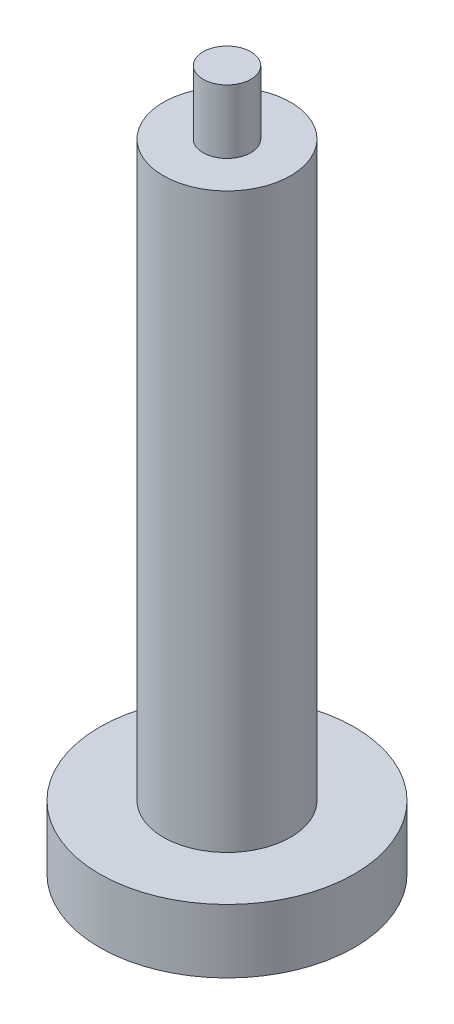
from build123d import *

# Parameters (mm, degrees)
SKETCH1_R                   = 25.4
BOSS_EXTRUDE1_DEPTH         = 63.5
SKETCH2_R                   = 25.4
SKETCH2_R_2                 = 12.7
CUT_EXTRUDE1_DEPTH          = 114.3
SKETCH3_R                   = 4.7625
BOSS_EXTRUDE2_DEPTH         = 12.7
SKETCH4_R                   = 19.05
CUT_EXTRUDE2_DEPTH          = 2.54
F_3_8_16_TAPPED_HOLE1_D     = 7.9375
F_3_8_16_TAPPED_HOLE1_DEPTH = 26.924
F_3_8_16_TAPPED_HOLE1_TIP   = 2.384665582


with BuildPart() as part:
    # Sketch1 → Boss-Extrude1 (new body, symmetric)
    with BuildSketch(Plane(origin=(0, 0, 0), x_dir=(1, 0, 0), z_dir=(0, 1, 0))):
        Circle(SKETCH1_R)
    extrude(amount=BOSS_EXTRUDE1_DEPTH, both=True)

    # Sketch2 → Cut-Extrude1 (cut)
    with BuildSketch(Plane(origin=(0, 63.5, 0), x_dir=(1, 0, 0), z_dir=(0, 1, 0))):
        Circle(SKETCH2_R)
        Circle(SKETCH2_R_2, mode=Mode.SUBTRACT)
    extrude(amount=-CUT_EXTRUDE1_DEPTH, mode=Mode.SUBTRACT)

    # Sketch3 → Boss-Extrude2 (add)
    with BuildSketch(Plane(origin=(0, 63.5, 0), x_dir=(1, 0, 0), z_dir=(0, 1, 0))):
        Circle(SKETCH3_R)
    extrude(amount=BOSS_EXTRUDE2_DEPTH)

    # Sketch4 → Cut-Extrude2 (cut)
    with BuildSketch(Plane.XZ.offset(63.5)):
        Circle(SKETCH4_R)
    extrude(amount=-CUT_EXTRUDE2_DEPTH, mode=Mode.SUBTRACT)

    # 3/8-16 Tapped Hole1
    with Locations(Plane(origin=(0, -60.96, 0), x_dir=(-1, 0, 0), z_dir=(0, -1, 0))):
        with Locations((0, 0)):
            Hole(F_3_8_16_TAPPED_HOLE1_D / 2, depth=F_3_8_16_TAPPED_HOLE1_DEPTH)
            with Locations((0, 0, -(F_3_8_16_TAPPED_HOLE1_DEPTH + F_3_8_16_TAPPED_HOLE1_TIP / 2))):  # 118° drill point
                Cone(0, F_3_8_16_TAPPED_HOLE1_D / 2, F_3_8_16_TAPPED_HOLE1_TIP, mode=Mode.SUBTRACT)


solid = part.part
